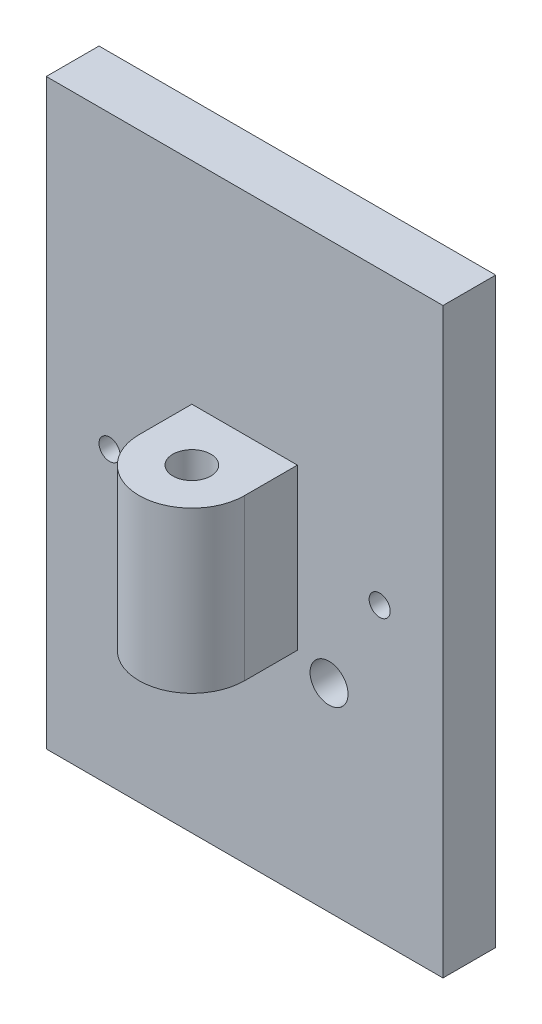
from build123d import *

# Parameters (mm, degrees)
SKETCH1_W               = 23.876
SKETCH1_H               = 35.052
SKETCH1_R               = 1.143
SKETCH1_R_2             = 0.635
BOSS_EXTRUDE1_DEPTH     = 3.175
SKETCH2_W               = 6.35
SKETCH2_H               = 9.652
BOSS_EXTRUDE2_DEPTH     = 9.525
SKETCH3_R               = 1.143
CUT_EXTRUDE2_DEPTH      = 36.052
CUT_EXTRUDE2_DEPTH_BACK = 6.35


with BuildPart() as part:
    # Sketch1 → Boss-Extrude1 (new body)
    with BuildSketch(Plane.XY):
        with Locations((11.938, 17.526)):
            Rectangle(SKETCH1_W, SKETCH1_H)
        with Locations((6.858, 11.938)):
            Circle(SKETCH1_R, mode=Mode.SUBTRACT)
        with Locations((17.018, 11.938)):
            Circle(SKETCH1_R, mode=Mode.SUBTRACT)
        with Locations((20.066, 17.526)):
            Circle(SKETCH1_R_2, mode=Mode.SUBTRACT)
        with Locations((3.81, 17.526)):
            Circle(SKETCH1_R_2, mode=Mode.SUBTRACT)
    extrude(amount=BOSS_EXTRUDE1_DEPTH)

    # Sketch2 → Boss-Extrude2 (add)
    with BuildSketch(Plane.XY):
        with Locations((11.938, 17.526)):
            Rectangle(SKETCH2_W, SKETCH2_H)
    extrude(amount=BOSS_EXTRUDE2_DEPTH)

    # Sketch3 → Cut-Extrude2 (cut, two sides)
    with BuildSketch(Plane(origin=(0, 0, 0), x_dir=(1, 0, 0), z_dir=(0, 1, 0))) as cut_extrude2_sk:
        with Locations((11.938, -6.35)):
            Circle(SKETCH3_R)
        with BuildLine():
            ThreePointArc((11.938, -9.525), (9.69293597, -8.59506403), (8.763, -6.35))
            Line((8.763, -6.35), (8.763, -9.525))
            Line((8.763, -9.525), (11.938, -9.525))
        make_face()
        with BuildLine():
            ThreePointArc((15.113, -6.35), (14.18306403, -8.59506403), (11.938, -9.525))
            Line((11.938, -9.525), (15.113, -9.525))
            Line((15.113, -9.525), (15.113, -6.35))
        make_face()
    extrude(amount=CUT_EXTRUDE2_DEPTH, mode=Mode.SUBTRACT)
    extrude(cut_extrude2_sk.sketch, amount=-CUT_EXTRUDE2_DEPTH_BACK, mode=Mode.SUBTRACT)


solid = part.part
